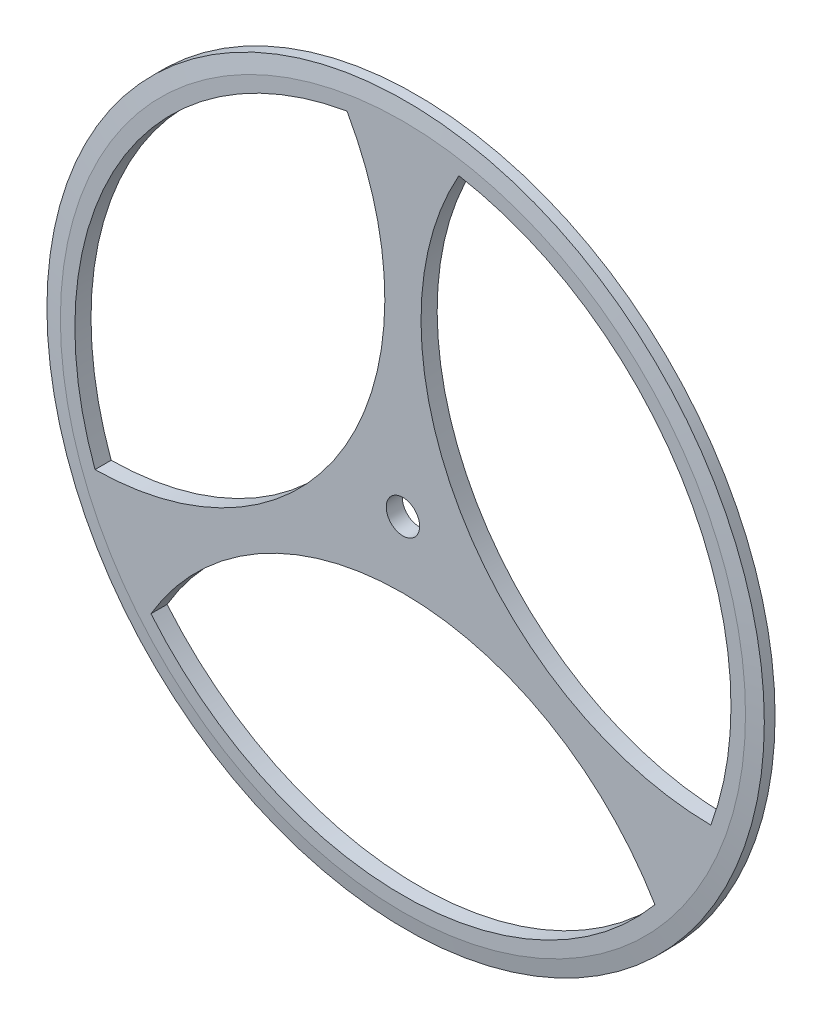
from build123d import *

# Parameters (mm, degrees)
SKETCH1_R               = 6.67
BOSS_EXTRUDE1_DEPTH     = 0.15
CHAMFER1_SIZE           = 0.3
CHAMFER1_SIZE2          = 0.05
CHAMFER2_SIZE           = 0.05
CHAMFER2_SIZE2          = 0.3
CUT_EXTRUDE1_DEPTH      = 10.433997032
CUT_EXTRUDE1_DEPTH_BACK = 10.433997032
SKETCH2_R               = 0.3105
CUT_EXTRUDE2_DEPTH      = 10.433997032
CIRPATTERN1_COUNT       = 3


with BuildPart() as part:
    # Sketch1 → Boss-Extrude1 (new, symmetric)
    with BuildSketch(Plane.XY):
        Circle(SKETCH1_R)
    extrude(amount=BOSS_EXTRUDE1_DEPTH, both=True)

    # Chamfer1
    chamfer1_edges = [part.edges().sort_by_distance(p)[0] for p in [
        (-6.67, 0, -0.15),
    ]]
    chamfer1_side = [part.faces().sort_by_distance(p)[0] for p in [
        (0, 0, -0.15),
    ]]
    chamfer(chamfer1_edges, length=CHAMFER1_SIZE, length2=CHAMFER1_SIZE2, reference=chamfer1_side[0])

    # Chamfer2
    chamfer2_edges = [part.edges().sort_by_distance(p)[0] for p in [
        (-6.67, 0, 0.15),
    ]]
    chamfer2_side = [part.faces().sort_by_distance(p)[0] for p in [
        (-6.67, 0, 0.025),
    ]]
    chamfer(chamfer2_edges, length=CHAMFER2_SIZE, length2=CHAMFER2_SIZE2, reference=chamfer2_side[0])

    # Sketch2 → Cut-Extrude1 (cut, two sides: drawn at the far end of the back side and taken through both)
    with BuildSketch(Plane.XY.offset(-CUT_EXTRUDE1_DEPTH_BACK)):
        Circle(SKETCH2_R)
    extrude(amount=CUT_EXTRUDE1_DEPTH + CUT_EXTRUDE1_DEPTH_BACK, mode=Mode.SUBTRACT)

    # Sketch3 → Cut-Extrude2 (cut, symmetric)
    with BuildSketch(Plane.XY):
        with BuildLine():
            ThreePointArc((1.039913882, 6.010705376), (1.065211247, 0.615), (5.725380491, -2.104760848))
            ThreePointArc((5.725380491, -2.104760848), (5.282754963, 3.05), (1.039913882, 6.010705376))
        make_face()
    cut_extrude2 = extrude(amount=CUT_EXTRUDE2_DEPTH, both=True, mode=Mode.SUBTRACT)

    # CirPattern1: Cut-Extrude2 ×3 about axis
    cirpattern1_axis = Axis((0, 0, -2.585842129), (0, 0, 1))
    for i in range(1, CIRPATTERN1_COUNT):
        add(cut_extrude2.rotate(cirpattern1_axis, i * 360 / CIRPATTERN1_COUNT), mode=Mode.SUBTRACT)


solid = part.part
